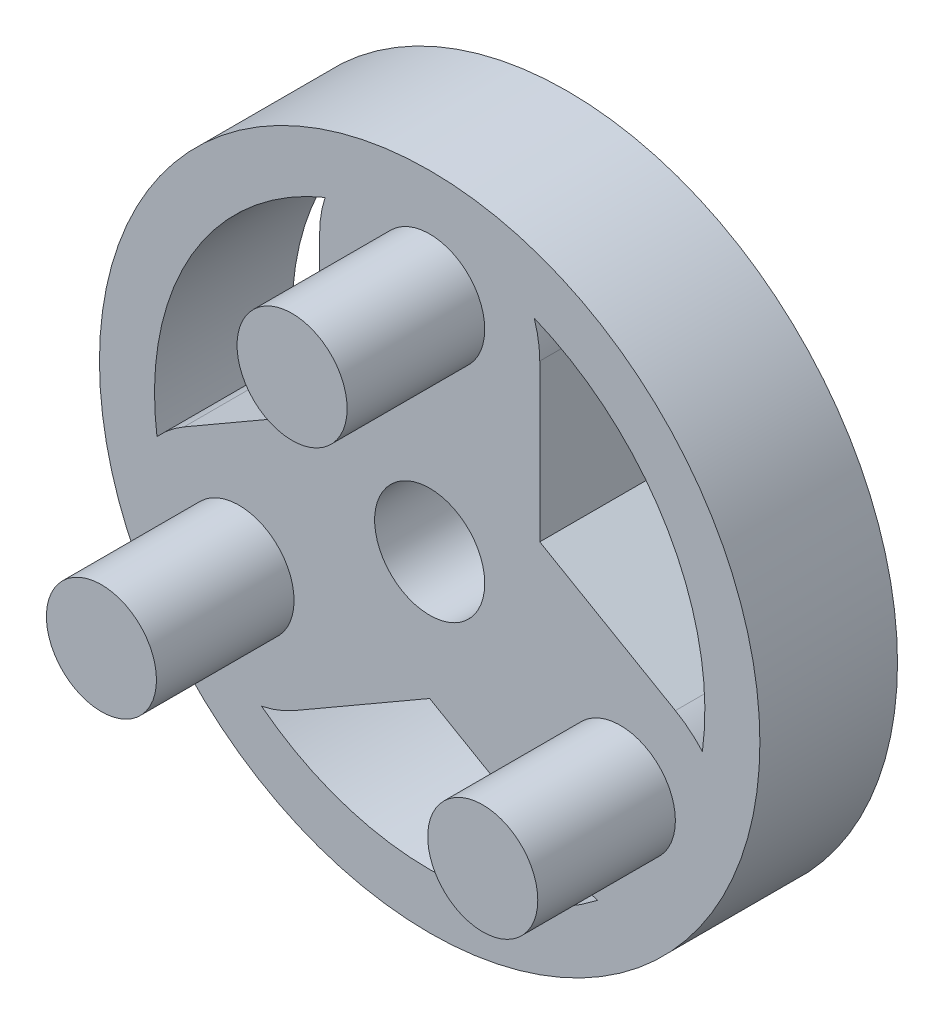
from build123d import *

# Parameters (mm, degrees)
BOSS_EXTRUDE1_DEPTH     = 5
SKETCH3_R               = 2
BOSS_EXTRUDE2_DEPTH     = 5
SKETCH4_R               = 2
CUT_EXTRUDE1_DEPTH      = 6
CUT_EXTRUDE1_DEPTH_BACK = 6
SKETCH5_R               = 12
SKETCH5_R_2             = 10
BOSS_EXTRUDE3_DEPTH     = 5


with BuildPart() as part:
    # Sketch1 → Boss-Extrude1 (new body)
    with BuildSketch(Plane.XY):
        with BuildLine():
            Line((4, 2.309401077), (4, 8))
            ThreePointArc((4, 8), (0, 12), (-4, 8))
            Line((-4, 8), (-4, 2.309401077))
            Line((-4, 2.309401077), (-8.92820323, -0.535898385))
            ThreePointArc((-8.92820323, -0.535898385), (-10.392304845, -6), (-4.92820323, -7.464101615))
            Line((-4.92820323, -7.464101615), (0, -4.618802154))
            Line((0, -4.618802154), (4.92820323, -7.464101615))
            ThreePointArc((4.92820323, -7.464101615), (10.392304845, -6), (8.92820323, -0.535898385))
            Line((8.92820323, -0.535898385), (4, 2.309401077))
        make_face()
    extrude(amount=BOSS_EXTRUDE1_DEPTH)

    # Sketch3 → Boss-Extrude2 (add)
    with BuildSketch(Plane.XY.offset(5)):
        with Locations((0, 8)):
            Circle(SKETCH3_R)
        with Locations((6.92820323, -4)):
            Circle(SKETCH3_R)
        with Locations((-6.92820323, -4)):
            Circle(SKETCH3_R)
        Circle(SKETCH3_R)
    extrude(amount=BOSS_EXTRUDE2_DEPTH)

    # Sketch4 → Cut-Extrude1 (cut, two sides)
    with BuildSketch(Plane.XY.offset(5)) as cut_extrude1_sk:
        Circle(SKETCH4_R)
    extrude(amount=CUT_EXTRUDE1_DEPTH, mode=Mode.SUBTRACT)
    extrude(cut_extrude1_sk.sketch, amount=-CUT_EXTRUDE1_DEPTH_BACK, mode=Mode.SUBTRACT)

    # Sketch5 → Boss-Extrude3 (add)
    with BuildSketch(Plane.XY.offset(5)):
        Circle(SKETCH5_R)
        Circle(SKETCH5_R_2, mode=Mode.SUBTRACT)
    extrude(amount=-BOSS_EXTRUDE3_DEPTH)


solid = part.part
